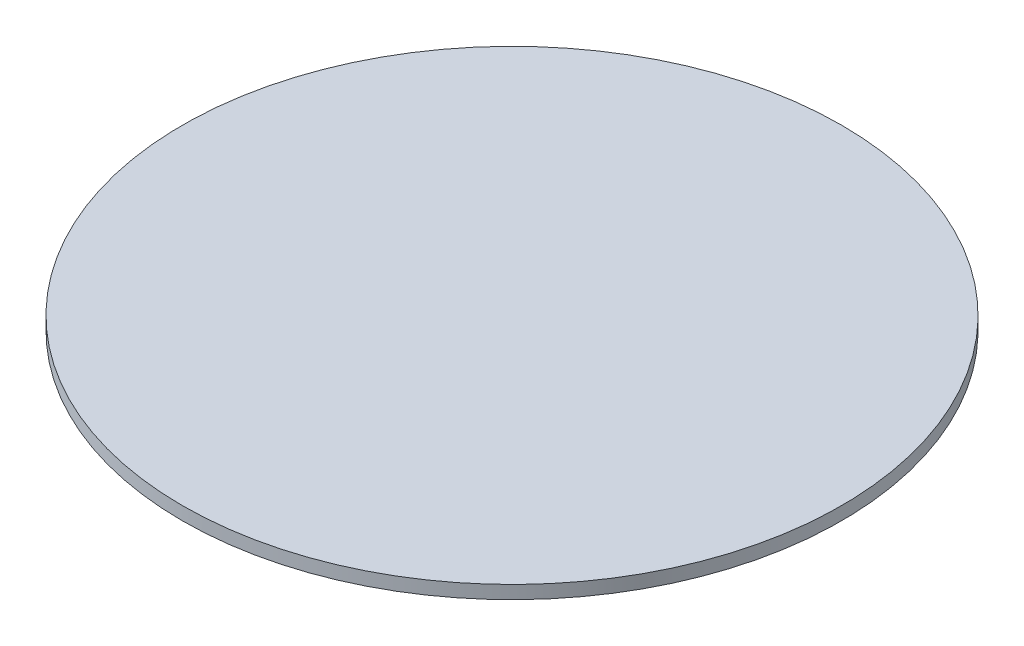
from build123d import *

# Parameters (mm, degrees)
ESBO_O1_R                = 1000
RESSALTO_EXTRUS_O1_DEPTH = 40


with BuildPart() as part:
    # Esboço1 → Ressalto-extrusão1 (new body)
    with BuildSketch(Plane(origin=(0, 0, 0), x_dir=(1, 0, 0), z_dir=(0, 1, 0))):
        Circle(ESBO_O1_R)
    extrude(amount=RESSALTO_EXTRUS_O1_DEPTH)


solid = part.part
